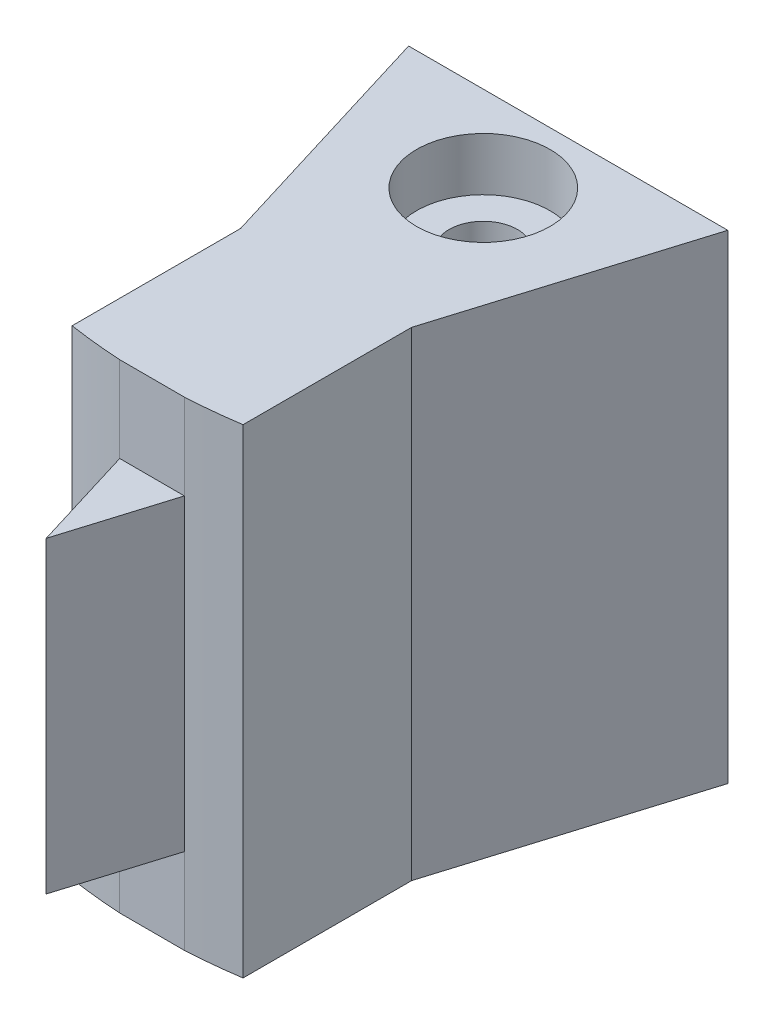
from build123d import *

# Parameters (mm, degrees)
BOSS_EXTRUDE1_DEPTH      = 12
BOSS_EXTRUDE1_DEPTH_BACK = 2
CUT_EXTRUDE1_DEPTH       = 5
SKETCH5_R                = 1
CUT_EXTRUDE2_DEPTH       = 7.26
CUT_EXTRUDE2_DEPTH_BACK  = 8.74
SKETCH6_R                = 1.95
CUT_EXTRUDE3_DEPTH       = 1.55
CUT_EXTRUDE4_DEPTH       = 2.5


with BuildPart() as part:
    # Sketch1 → Boss-Extrude1 (new body, two sides)
    with BuildSketch(Plane(origin=(0, 0, 0), x_dir=(1, 0, 0), z_dir=(0, 1, 0))) as boss_extrude1_sk:
        with BuildLine():
            Line((4.642363604, -4.565370009), (-4.68242218, -4.565370009))
            Line((-4.68242218, -4.565370009), (-2.520029288, -11.638238463))
            Line((-2.520029288, -11.638238463), (-2.520029288, -16.559323376))
            ThreePointArc((-2.520029288, -16.559323376), (-1.744780523, -16.658855879), (-0.965732534, -16.722114069))
            Line((-0.965732534, -16.722114069), (-0.020029288, -19.815370009))
            Line((-0.020029288, -19.815370009), (0.924969464, -16.724418368))
            ThreePointArc((0.924969464, -16.724418368), (1.704326405, -16.663043233), (2.479970712, -16.565370009))
            Line((2.479970712, -16.565370009), (2.479970712, -11.638238463))
            Line((2.479970712, -11.638238463), (4.642363604, -4.565370009))
        make_face()
    extrude(amount=BOSS_EXTRUDE1_DEPTH)
    extrude(boss_extrude1_sk.sketch, amount=-BOSS_EXTRUDE1_DEPTH_BACK)

    # Sketch2 → Cut-Extrude1 (cut)
    with BuildSketch(Plane(origin=(0, 0, 4.565370009), x_dir=(-1, 0, 0), z_dir=(0, 0, -1))):
        with BuildLine():
            Line((-2.878246061, 5.95), (2.918304637, 5.95))
            ThreePointArc((2.918304637, 5.95), (0.020029288, 8.05), (-2.878246061, 5.95))
        make_face()
        with BuildLine():
            Line((-2.878246061, 4.05), (2.918304637, 4.05))
            ThreePointArc((2.918304637, 4.05), (0.020029288, 1.95), (-2.878246061, 4.05))
        make_face()
    extrude(amount=-CUT_EXTRUDE1_DEPTH, mode=Mode.SUBTRACT)

    # Sketch5 → Cut-Extrude2 (cut, two sides)
    with BuildSketch(Plane(origin=(0, 5.74, 0), x_dir=(1, 0, 0), z_dir=(0, 1, 0))) as cut_extrude2_sk:
        with Locations((0, -7.065370009)):
            Circle(SKETCH5_R)
    extrude(amount=CUT_EXTRUDE2_DEPTH, mode=Mode.SUBTRACT)
    extrude(cut_extrude2_sk.sketch, amount=-CUT_EXTRUDE2_DEPTH_BACK, mode=Mode.SUBTRACT)

    # Sketch6 → Cut-Extrude3 (cut)
    with BuildSketch(Plane(origin=(0, 12, 0), x_dir=(1, 0, 0), z_dir=(0, 1, 0))):
        with Locations((0, -7.065370009)):
            Circle(SKETCH6_R)
    extrude(amount=-CUT_EXTRUDE3_DEPTH, mode=Mode.SUBTRACT)

    # Sketch7 → Cut-Extrude4 (cut)
    with BuildSketch(Plane(origin=(0, 12, 0), x_dir=(1, 0, 0), z_dir=(0, 1, 0))):
        Polygon((0.924969464, -16.724418368), (-0.020029288, -19.815370009), (-0.965732534, -16.722114069), align=None)
    cut_extrude4 = extrude(amount=-CUT_EXTRUDE4_DEPTH, mode=Mode.SUBTRACT)

    # Mirror1: Cut-Extrude4 across plane
    add(cut_extrude4.mirror(Plane.ZX.offset(5)), mode=Mode.SUBTRACT)


solid = part.part
